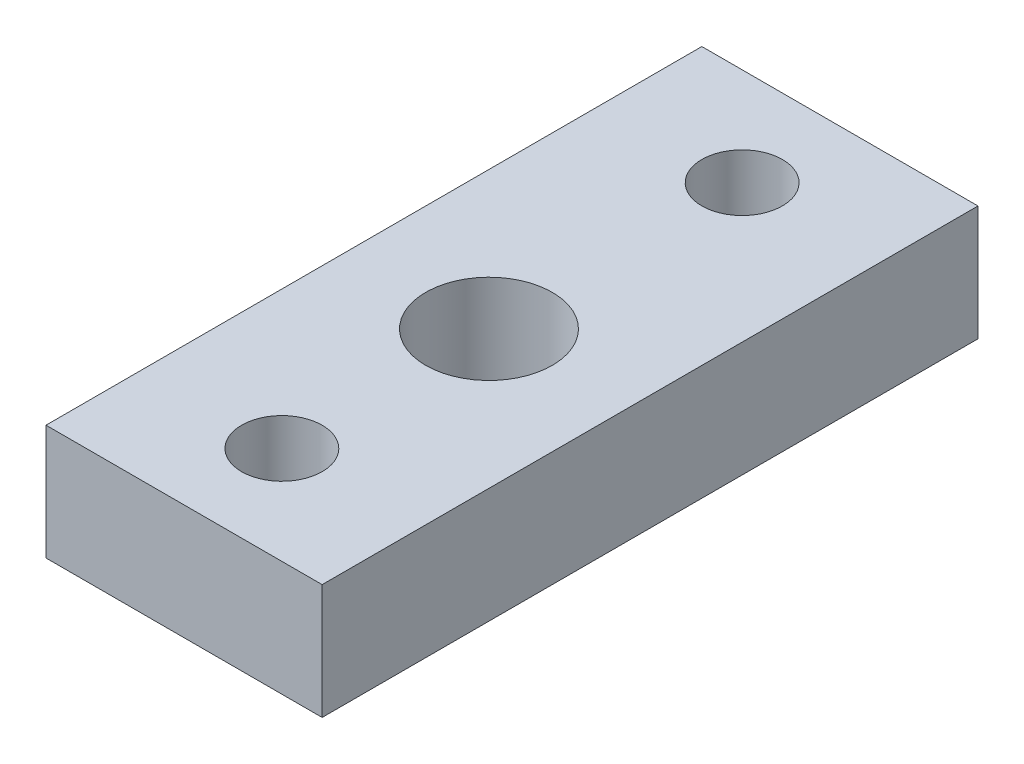
from build123d import *

# Parameters (mm, degrees)
SKETCH1_W           = 12
SKETCH1_H           = 28.5
SKETCH1_R           = 1.75
SKETCH1_R_2         = 2.75
BOSS_EXTRUDE1_DEPTH = 5


with BuildPart() as part:
    # Sketch1 → Boss-Extrude1 (new body)
    with BuildSketch(Plane(origin=(0, 0, 0), x_dir=(1, 0, 0), z_dir=(0, 1, 0))):
        with Locations((6, 14.25)):
            Rectangle(SKETCH1_W, SKETCH1_H)
        with Locations((6, 24.25)):
            Circle(SKETCH1_R, mode=Mode.SUBTRACT)
        with Locations((6, 4.25)):
            Circle(SKETCH1_R, mode=Mode.SUBTRACT)
        with Locations((6, 13.25)):
            Circle(SKETCH1_R_2, mode=Mode.SUBTRACT)
    extrude(amount=BOSS_EXTRUDE1_DEPTH)


solid = part.part
